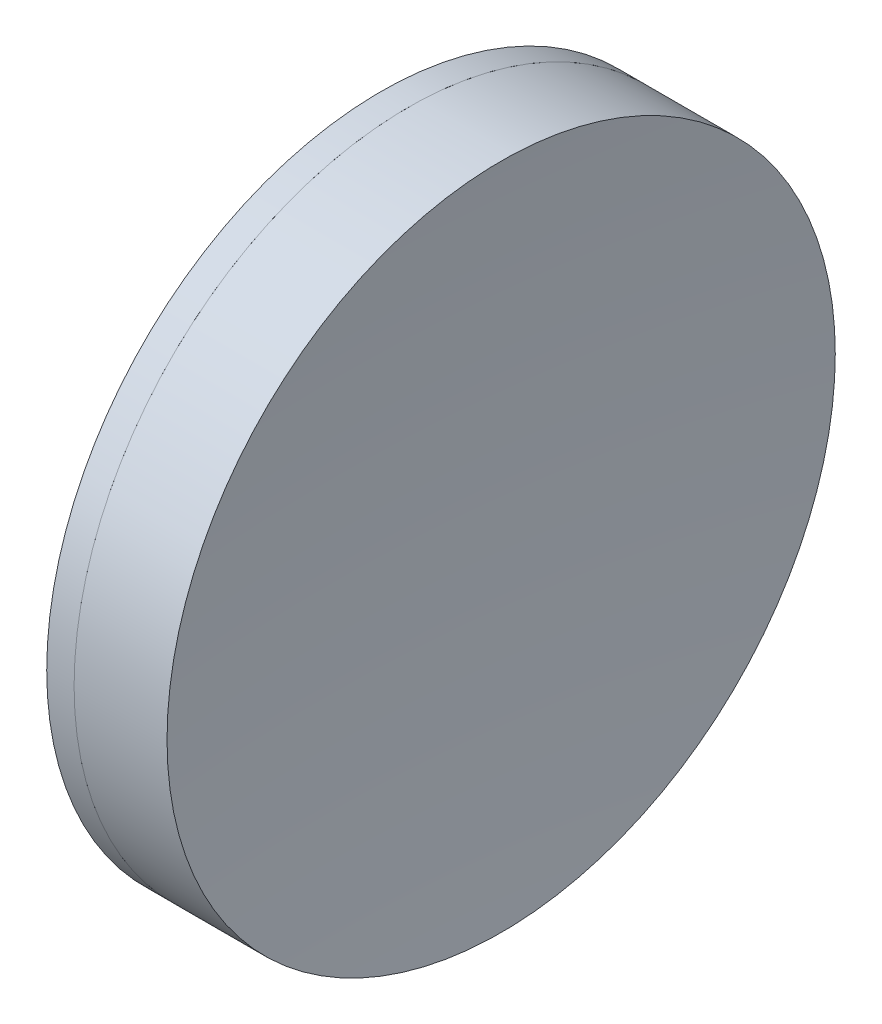
from build123d import *


with BuildPart() as part:
    # 草图1 one side → 旋转1 (revolve)
    with BuildSketch(Plane(origin=(0, 0, 0), x_dir=(1, 0, 0), z_dir=(0, 1, 0)), mode=Mode.PRIVATE) as revolve_1_sk:
        with BuildLine():
            ThreePointArc((151.580807275, 25.4), (148.955414292, 12.82041638), (148.074768961, 0))
            Line((148.074768961, 0), (156.574768961, 0))
            ThreePointArc((156.574768961, 0), (155.844243784, 12.78322312), (153.662180184, 25.4))
            Line((153.662180184, 25.4), (151.580807275, 25.4))
        make_face()
    revolve(revolve_1_sk.sketch.rotate(Axis((-0.816062176, 0, 0), (1, 0, 0)), 180), axis=Axis((-0.816062176, 0, 0), (1, 0, 0)))  # turned: the seam where the file's is


with BuildPart() as body_2:
    # 草图2 one side → 旋转2 (revolve)
    with BuildSketch(Plane(origin=(0, 0, 0), x_dir=(1, 0, 0), z_dir=(0, 1, 0)), mode=Mode.PRIVATE) as revolve_2_sk:
        with BuildLine():
            Line((160.726947746, 25.4), (153.662180184, 25.4))
            ThreePointArc((153.662180184, 25.4), (155.844243784, 12.78322312), (156.574768961, 0))
            Line((156.574768961, 0), (159.574768961, 0))
            ThreePointArc((159.574768961, 0), (159.862961679, 12.713059387), (160.726947746, 25.4))
        make_face()
    revolve(revolve_2_sk.sketch.rotate(Axis((-0.551919993, 0, 0), (1, 0, 0)), 180), axis=Axis((-0.551919993, 0, 0), (1, 0, 0)))  # turned: the seam where the file's is


solid = Compound([part.part, body_2.part])
